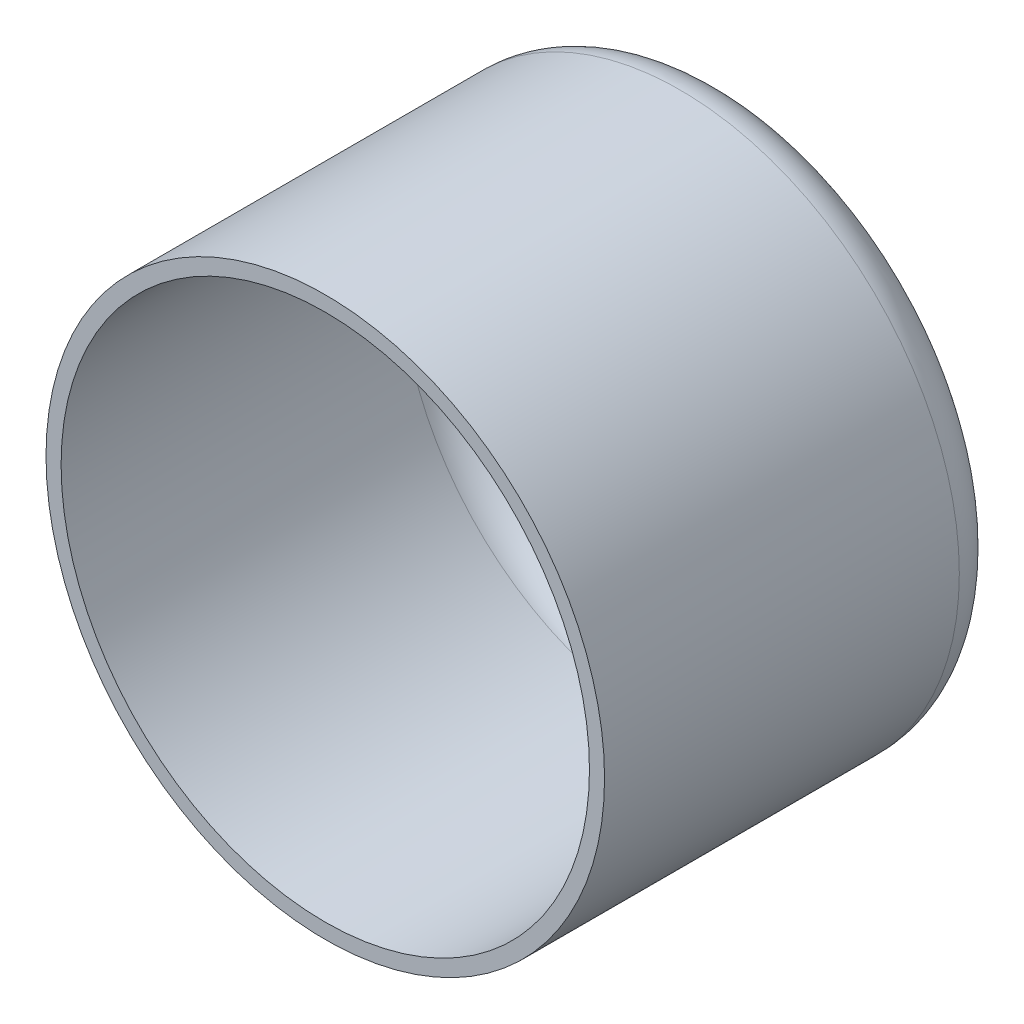
from build123d import *

# Parameters (mm, degrees)
SKETCH1_R      = 18.5
SKETCH1_R_2    = 6
EXTRUDE1_DEPTH = 1
SKETCH2_R      = 18.5
SKETCH2_R_2    = 17.5
EXTRUDE2_DEPTH = 25.5
FILLET1_R      = 3


with BuildPart() as part:
    # Sketch1 → Extrude1 (new body)
    with BuildSketch(Plane.XY):
        Circle(SKETCH1_R)
        with Locations((0.338070115, -7.192058718)):
            Circle(SKETCH1_R_2, mode=Mode.SUBTRACT)
    extrude(amount=EXTRUDE1_DEPTH)

    # Sketch2 → Extrude2 (add)
    with BuildSketch(Plane.XY.offset(1)):
        Circle(SKETCH2_R)
        Circle(SKETCH2_R_2, mode=Mode.SUBTRACT)
    extrude(amount=EXTRUDE2_DEPTH)

    # Fillet1
    fillet1_edges = [part.edges().sort_by_distance(p)[0] for p in [
        (-18.5, 0, 0),
        (-17.5, 0, 1),
    ]]
    fillet(fillet1_edges, radius=FILLET1_R)


solid = part.part
